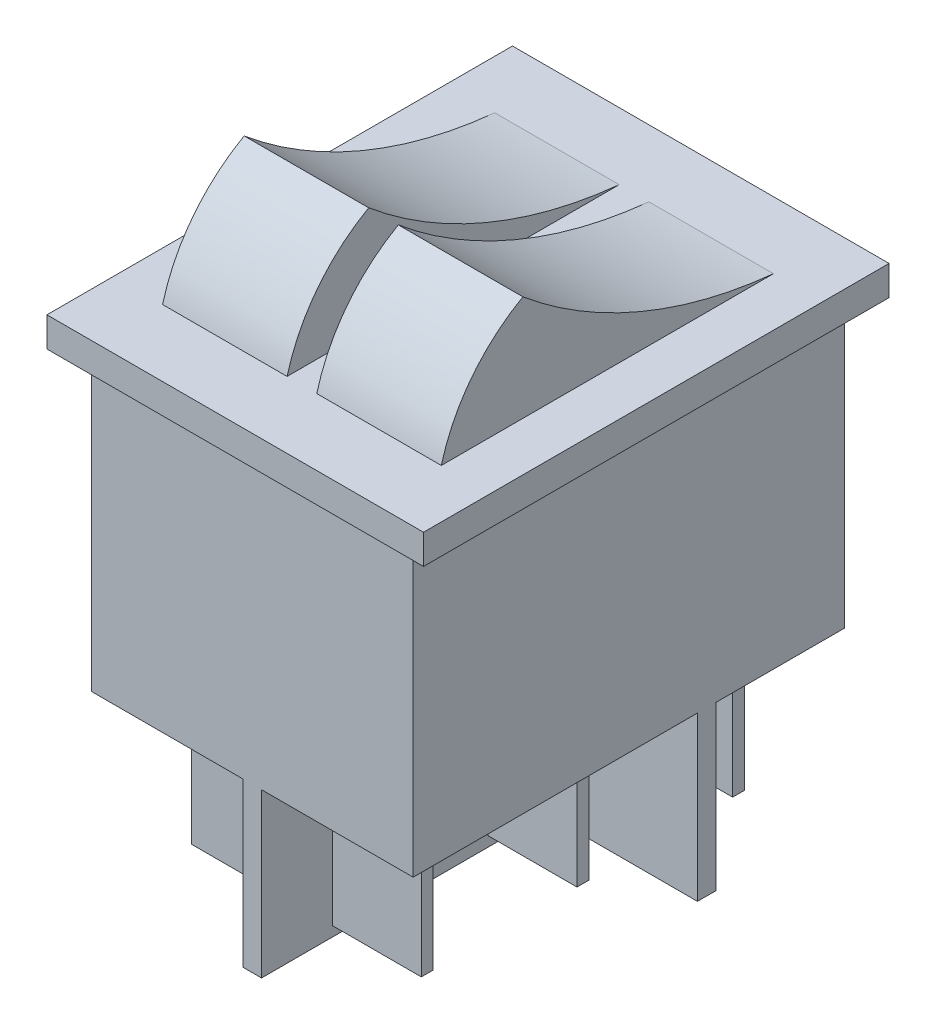
from build123d import *

# Parameters (mm, degrees)
CROQUIS1_W              = 25.4
CROQUIS1_H              = 31.4
SALIENTE_EXTRUIR1_DEPTH = 2
SALIENTE_EXTRUIR2_START = 1
SALIENTE_EXTRUIR2_DEPTH = 8.4
CROQUIS3_W              = 21.7
CROQUIS3_H              = 29.1
SALIENTE_EXTRUIR3_DEPTH = 19.65
CROQUIS4_W              = 6
CROQUIS4_H              = 0.8
SALIENTE_EXTRUIR4_DEPTH = 9.2
SALIENTE_EXTRUIR5_DEPTH = 11


with BuildPart() as part:
    # Croquis1 → Saliente-Extruir1 (new body)
    with BuildSketch(Plane(origin=(0, 0, 0), x_dir=(1, 0, 0), z_dir=(0, 1, 0))):
        Rectangle(CROQUIS1_W, CROQUIS1_H)
    extrude(amount=SALIENTE_EXTRUIR1_DEPTH)

    # Croquis2 → Saliente-Extruir2 (add)
    with BuildSketch(Plane(origin=(0, 0, 0), x_dir=(0, 0, -1), z_dir=(1, 0, 0)).offset(SALIENTE_EXTRUIR2_START)):
        with BuildLine():
            Line((-11.2, 2), (11.2, 2))
            ThreePointArc((11.2, 2), (2.215809273, 4.278475594), (-5.7, 9.1))
            ThreePointArc((-5.7, 9.1), (-9.165424158, 6.104201813), (-11.2, 2))
        make_face()
    saliente_extruir2 = extrude(amount=SALIENTE_EXTRUIR2_DEPTH)

    # Simetría1: Saliente-Extruir2 across plane
    add(saliente_extruir2.mirror(Plane(origin=(0, 0, 0), x_dir=(0, 0, 1), z_dir=(1, 0, 0))))

    # Croquis3 → Saliente-Extruir3 (add)
    with BuildSketch(Plane.XZ):
        Rectangle(CROQUIS3_W, CROQUIS3_H)
    extrude(amount=SALIENTE_EXTRUIR3_DEPTH)

    # Croquis4 → Saliente-Extruir4 (add)
    with BuildSketch(Plane.XZ.offset(19.65)):
        with Locations((4.75, 10.5)):
            Rectangle(CROQUIS4_W, CROQUIS4_H)
        with Locations((-4.75, 10.5)):
            Rectangle(CROQUIS4_W, CROQUIS4_H)
        with Locations((4.75, 0)):
            Rectangle(CROQUIS4_W, CROQUIS4_H)
        with Locations((4.75, -10.5)):
            Rectangle(CROQUIS4_W, CROQUIS4_H)
        with Locations((-4.75, 0)):
            Rectangle(CROQUIS4_W, CROQUIS4_H)
        with Locations((-4.75, -10.5)):
            Rectangle(CROQUIS4_W, CROQUIS4_H)
    extrude(amount=SALIENTE_EXTRUIR4_DEPTH)

    # Croquis5 → Saliente-Extruir5 (add)
    with BuildSketch(Plane.XZ.offset(19.65)):
        Polygon((0.625, 14.55), (-0.625, 14.55), (-0.625, -4.625), (-10.85, -4.625), (-10.85, -5.875), (-0.625, -5.875), (-0.625, -14.55), (0.625, -14.55), (0.625, -5.875), (10.85, -5.875), (10.85, -4.625), (0.625, -4.625), align=None)
    extrude(amount=SALIENTE_EXTRUIR5_DEPTH)


solid = part.part
